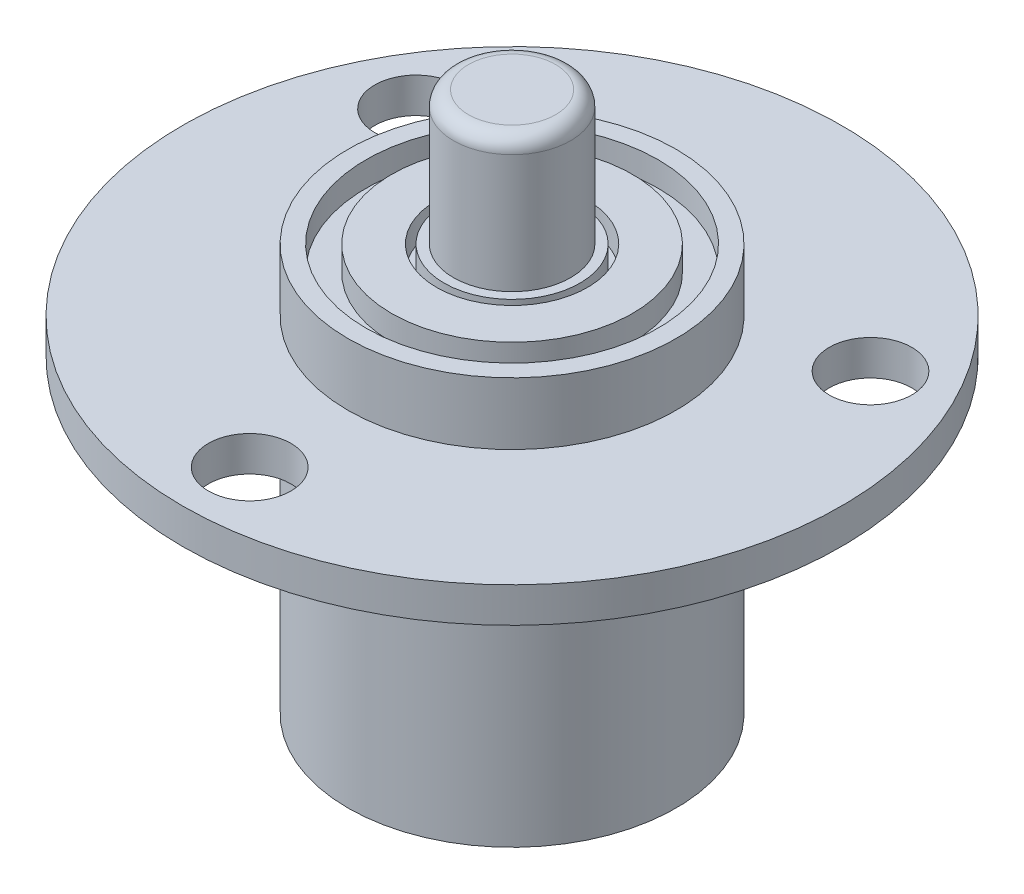
from build123d import *

# Parameters (mm, degrees)
SKETCH1_R                = 21.95
BOSS_EXTRUDE1_DEPTH      = 2.34
SKETCH2_R                = 10.925
BOSS_EXTRUDE2_DEPTH      = 4.14
BOSS_EXTRUDE2_DEPTH_BACK = 22.94
SKETCH3_R                = 2.75
CUT_EXTRUDE1_DEPTH       = 7.48
CIRPATTERN1_COUNT        = 3
SKETCH4_R                = 9.725
SKETCH4_R_2              = 8.025
SKETCH4_R_3              = 5.025
SKETCH4_R_4              = 4.525
CUT_EXTRUDE2_DEPTH       = 1.65
SKETCH5_R                = 3.9
BOSS_EXTRUDE3_DEPTH      = 8.9
FILLET1_R                = 1


with BuildPart() as part:
    # Sketch1 → Boss-Extrude1 (new body)
    with BuildSketch(Plane(origin=(0, 0, 0), x_dir=(1, 0, 0), z_dir=(0, 1, 0))):
        Circle(SKETCH1_R)
    extrude(amount=BOSS_EXTRUDE1_DEPTH)

    # Sketch2 → Boss-Extrude2 (add, two sides)
    with BuildSketch(Plane(origin=(0, 2.34, 0), x_dir=(1, 0, 0), z_dir=(0, 1, 0))) as boss_extrude2_sk:
        Circle(SKETCH2_R)
    extrude(amount=BOSS_EXTRUDE2_DEPTH)
    extrude(boss_extrude2_sk.sketch, amount=-BOSS_EXTRUDE2_DEPTH_BACK)

    # Sketch3 → Cut-Extrude1 (cut, through all)
    with BuildSketch(Plane.XZ):
        with Locations((0, 17.475)):
            Circle(SKETCH3_R)
    cut_extrude1 = extrude(amount=-CUT_EXTRUDE1_DEPTH, mode=Mode.SUBTRACT)

    # CirPattern1: Cut-Extrude1 ×3 about axis
    cirpattern1_axis = Axis((0, 0, 0), (0, 1, 0))
    for i in range(1, CIRPATTERN1_COUNT):
        add(cut_extrude1.rotate(cirpattern1_axis, i * 360 / CIRPATTERN1_COUNT), mode=Mode.SUBTRACT)

    # Sketch4 → Cut-Extrude2 (cut)
    with BuildSketch(Plane(origin=(0, 6.48, 0), x_dir=(1, 0, 0), z_dir=(0, 1, 0))):
        Circle(SKETCH4_R)
        Circle(SKETCH4_R_2, mode=Mode.SUBTRACT)
        Circle(SKETCH4_R_3)
        Circle(SKETCH4_R_4, mode=Mode.SUBTRACT)
    extrude(amount=-CUT_EXTRUDE2_DEPTH, mode=Mode.SUBTRACT)

    # Sketch5 → Boss-Extrude3 (add)
    with BuildSketch(Plane(origin=(0, 6.48, 0), x_dir=(1, 0, 0), z_dir=(0, 1, 0))):
        Circle(SKETCH5_R)
    extrude(amount=BOSS_EXTRUDE3_DEPTH)

    # Fillet1
    fillet1_edges = [part.edges().sort_by_distance(p)[0] for p in [
        (-3.9, 15.38, 0),
    ]]
    fillet(fillet1_edges, radius=FILLET1_R)


solid = part.part
